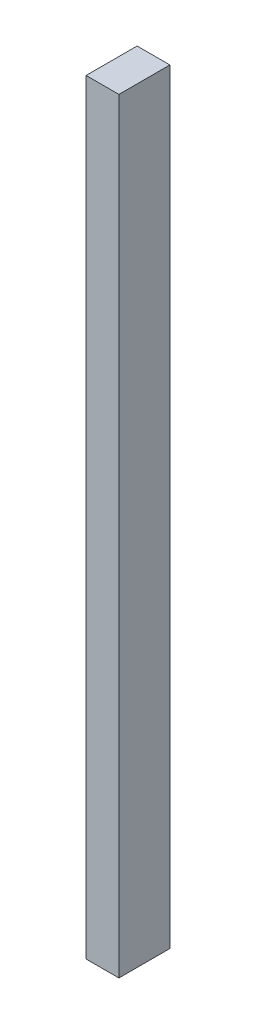
from build123d import *

# Parameters (mm, degrees)
SKETCH1_W           = 45
SKETCH1_H           = 70
BOSS_EXTRUDE1_DEPTH = 1050


with BuildPart() as part:
    # Sketch1 → Boss-Extrude1 (new body)
    with BuildSketch(Plane(origin=(0, 0, 0), x_dir=(1, 0, 0), z_dir=(0, 1, 0))):
        with Locations((22.5, 35)):
            Rectangle(SKETCH1_W, SKETCH1_H)
    extrude(amount=BOSS_EXTRUDE1_DEPTH)


solid = part.part
